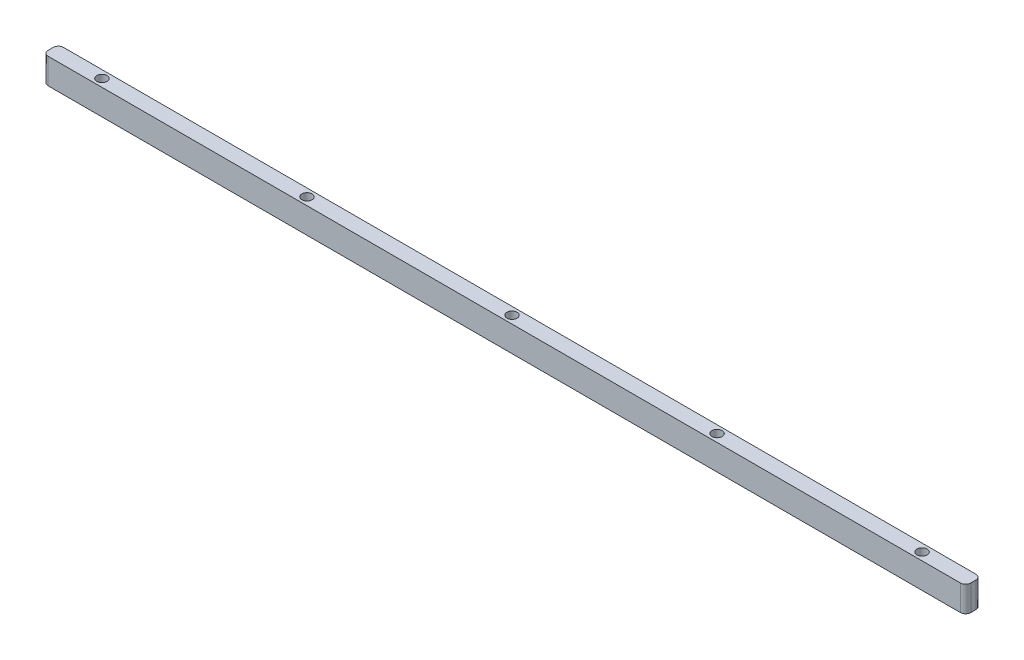
from build123d import *

# Parameters (mm, degrees)
SKETCH1_W           = 180
SKETCH1_H           = 3
SKETCH1_R           = 1
BOSS_EXTRUDE1_DEPTH = 5
FILLET1_R           = 1


with BuildPart() as part:
    # Sketch1 → Boss-Extrude1 (new body)
    with BuildSketch(Plane(origin=(0, 0, 0), x_dir=(1, 0, 0), z_dir=(0, 1, 0))):
        Rectangle(SKETCH1_W, SKETCH1_H)
        Circle(SKETCH1_R, mode=Mode.SUBTRACT)
        with Locations((40, 0)):
            Circle(SKETCH1_R, mode=Mode.SUBTRACT)
        with Locations((80, 0)):
            Circle(SKETCH1_R, mode=Mode.SUBTRACT)
        with Locations((-40, 0)):
            Circle(SKETCH1_R, mode=Mode.SUBTRACT)
        with Locations((-80, 0)):
            Circle(SKETCH1_R, mode=Mode.SUBTRACT)
    extrude(amount=BOSS_EXTRUDE1_DEPTH)

    # Fillet1
    fillet1_edges = [part.edges().sort_by_distance(p)[0] for p in [
        (-90, 2.5, 1.5),
        (-90, 2.5, -1.5),
        (90, 2.5, 1.5),
        (90, 2.5, -1.5),
    ]]
    fillet(fillet1_edges, radius=FILLET1_R)


solid = part.part
